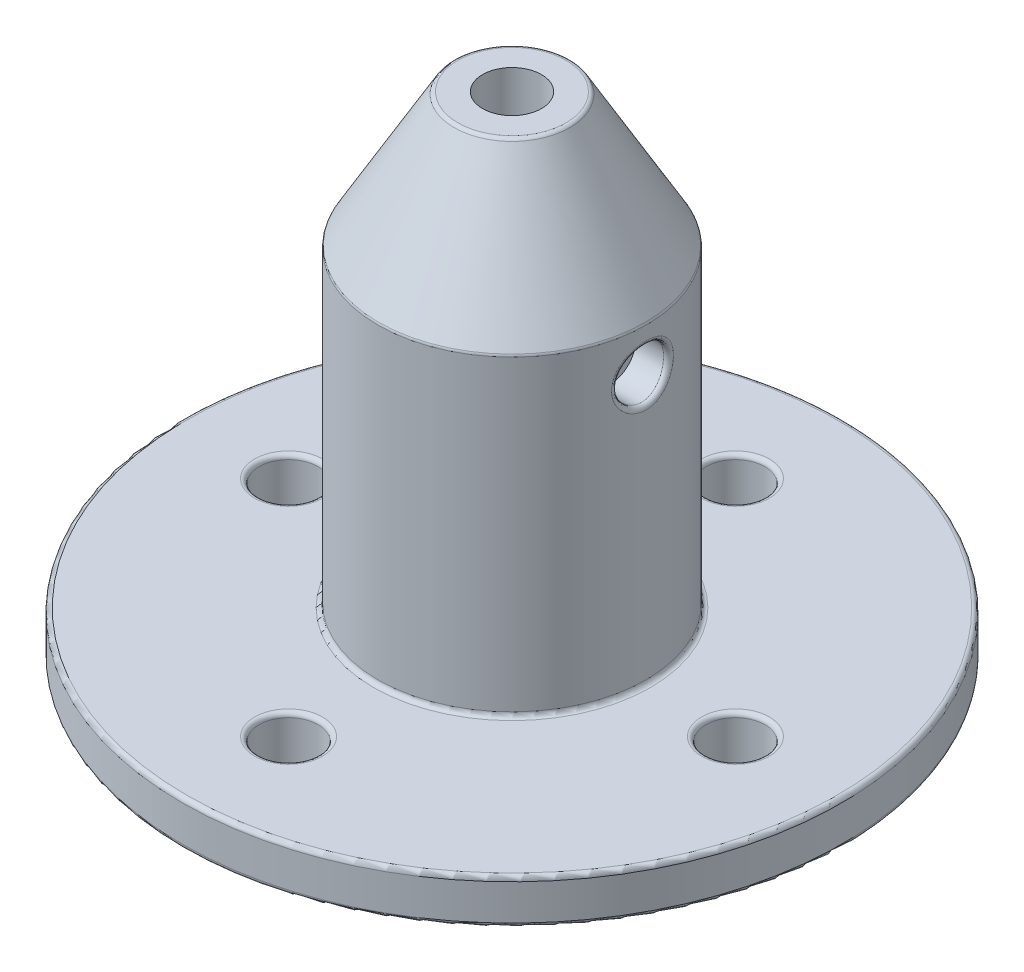
from build123d import *

# Parameters (mm, degrees)
SKETCH1_R               = 36.875
BOSS_EXTRUDE1_DEPTH     = 5
SKETCH2_R               = 15
SKETCH2_R_2             = 3.3
BOSS_EXTRUDE2_DEPTH     = 50
M6_CLEARANCE_HOLE1_D    = 6.6
CHAMFER1_SIZE           = 15
CHAMFER1_SIZE2          = 8.660254038
CUT_EXTRUDE3_DEPTH      = 79.886191757
CUT_EXTRUDE3_DEPTH_BACK = 6
SKETCH8_R               = 1.6
CUT_EXTRUDE4_DEPTH      = 80.906179374
CUT_EXTRUDE4_DEPTH_BACK = 6
SKETCH9_R               = 1.6
CUT_EXTRUDE1_DEPTH      = 1.38
CUT_EXTRUDE2_DEPTH      = 1.38
SKETCH11_R              = 2.85
CUT_EXTRUDE5_DEPTH      = 82.711573605
SKETCH13_R              = 2.85
CUT_EXTRUDE6_DEPTH      = 84.508798158
FILLET1_R               = 0.5


with BuildPart() as part:
    # Sketch1 → Boss-Extrude1 (new body)
    with BuildSketch(Plane(origin=(0, 0, 0), x_dir=(1, 0, 0), z_dir=(0, 1, 0))):
        Circle(SKETCH1_R)
    extrude(amount=BOSS_EXTRUDE1_DEPTH)

    # Sketch2 → Boss-Extrude2 (add)
    with BuildSketch(Plane(origin=(0, 5, 0), x_dir=(1, 0, 0), z_dir=(0, 1, 0))):
        Circle(SKETCH2_R)
        Circle(SKETCH2_R_2, mode=Mode.SUBTRACT)
    extrude(amount=BOSS_EXTRUDE2_DEPTH)

    # M6 Clearance Hole1 (through all)
    with Locations(Plane(origin=(0, 5, 0), x_dir=(1, 0, 0), z_dir=(0, 1, 0))):
        with Locations((0, -25), (-25, 0), (0, 25), (25, 0)):
            Hole(M6_CLEARANCE_HOLE1_D / 2)

    # Chamfer1
    chamfer1_edges = [part.edges().sort_by_distance(p)[0] for p in [
        (-15, 55, 0),
    ]]
    chamfer1_side = [part.faces().sort_by_distance(p)[0] for p in [
        (-15, 30, 0),
    ]]
    chamfer(chamfer1_edges, length=CHAMFER1_SIZE, length2=CHAMFER1_SIZE2, reference=chamfer1_side[0])

    # Sketch8 → Cut-Extrude3 (cut, two sides: drawn at the far end of the back side and taken through both)
    with BuildSketch(Plane(origin=(6, 0, 0), x_dir=(0, 0, -1), z_dir=(1, 0, 0)).offset(-CUT_EXTRUDE3_DEPTH_BACK)):
        with Locations((0, 35)):
            Circle(SKETCH8_R)
    extrude(amount=CUT_EXTRUDE3_DEPTH + CUT_EXTRUDE3_DEPTH_BACK, mode=Mode.SUBTRACT)

    # Sketch9 → Cut-Extrude4 (cut, two sides: drawn at the far end of the back side and taken through both)
    with BuildSketch(Plane(origin=(-5.196152423, 0, 3), x_dir=(0, -1, 0), z_dir=(-0.8660254037844398, 0, 0.499999999999998)).offset(-CUT_EXTRUDE4_DEPTH_BACK)):
        with Locations((-35, 0)):
            Circle(SKETCH9_R)
    extrude(amount=CUT_EXTRUDE4_DEPTH + CUT_EXTRUDE4_DEPTH_BACK, mode=Mode.SUBTRACT)

    # Sketch5 → Cut-Extrude1 (cut, symmetric)
    with BuildSketch(Plane(origin=(6, 0, 0), x_dir=(0, 0, -1), z_dir=(1, 0, 0))):
        Polygon((0, 38.417913594), (-2.96, 36.708956797), (-2.96, 33.291043203), (0, 31.582086406), (2.96, 33.291043203), (2.96, 36.708956797), align=None)
    extrude(amount=CUT_EXTRUDE1_DEPTH, both=True, mode=Mode.SUBTRACT)

    # Sketch6 → Cut-Extrude2 (cut, symmetric)
    with BuildSketch(Plane(origin=(-5.196152423, 0, 3), x_dir=(0, -1, 0), z_dir=(-0.8660254037844398, 0, 0.499999999999998))):
        Polygon((-31.582086406, 0), (-33.291043203, 2.96), (-36.708956797, 2.96), (-38.417913594, 0), (-36.708956797, -2.96), (-33.291043203, -2.96), align=None)
    extrude(amount=CUT_EXTRUDE2_DEPTH, both=True, mode=Mode.SUBTRACT)

    # Sketch11 → Cut-Extrude5 (cut, through all)
    with BuildSketch(Plane(origin=(11, 0, 0), x_dir=(0, 0, -1), z_dir=(1, 0, 0))):
        with Locations((0, 35)):
            Circle(SKETCH11_R)
    extrude(amount=CUT_EXTRUDE5_DEPTH, mode=Mode.SUBTRACT)

    # Sketch13 → Cut-Extrude6 (cut, through all)
    with BuildSketch(Plane(origin=(-9.526279442, 0, 5.5), x_dir=(0, -1, 0), z_dir=(-0.8660254037844398, 0, 0.499999999999998))):
        with Locations((-35, 0)):
            Circle(SKETCH13_R)
    extrude(amount=CUT_EXTRUDE6_DEPTH, mode=Mode.SUBTRACT)

    # Fillet1
    fillet1_edges = [part.edges().sort_by_distance(p)[0] for p in [
        (-21.7, 5, 0),
        (3.3, 5, 25),
        (28.3, 5, 0),
        (3.3, 5, -25),
        (-36.875, 0, 0),
        (-36.875, 5, 0),
        (-15, 5, 0),
        (-15, 40, 0),
        (-6.339745962, 55, 0),
        (-12.990381057, 37.85, 7.5),
        (14.864004718, 37.01522617, -2.015282509),
    ]]
    fillet(fillet1_edges, radius=FILLET1_R)


solid = part.part
